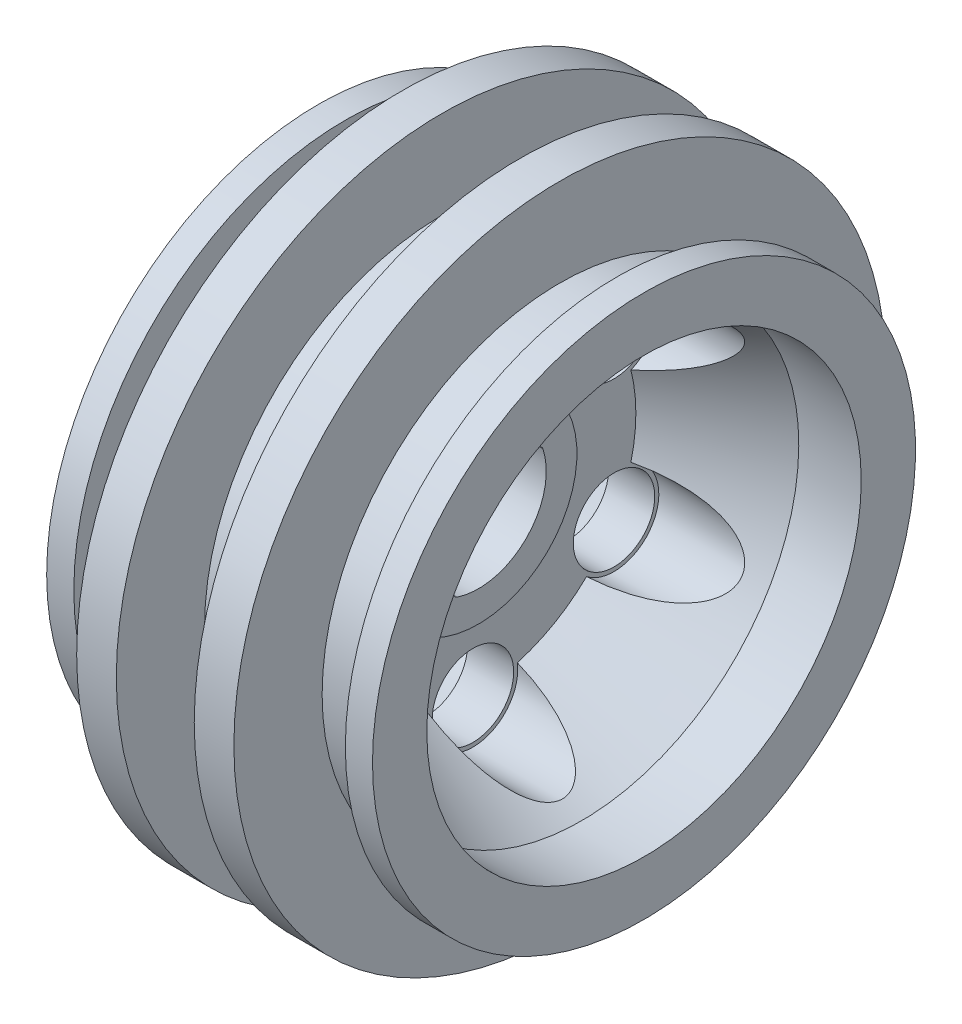
from build123d import *

# Parameters (mm, degrees)
CUT_EXTRUDE1_REACH        = 14.668
SKETCH2_R                 = 1.5
CUT_EXTRUDE2_REACH        = 15.519
SKETCH4_R                 = 1.65
CUT_EXTRUDE3_DEPTH        = 14.629380147
FILLET1_R                 = 0.2
CUT_EXTRUDE4_REACH        = 14.668
CUT_EXTRUDE5_DEPTH        = 0.5
CIRPATTERN1_COUNT         = 6
CIRPATTERN2_COUNT         = 6
CIRPATTERN2_COPY_1_REACH  = 14.668
CIRPATTERN2_COPY_2_REACH  = 14.668
CIRPATTERN2_COPY_3_REACH  = 14.668
CIRPATTERN2_COPY_4_REACH  = 14.668
CIRPATTERN2_COPY_5_REACH  = 14.668
CIRPATTERN2_COPY_6_REACH  = 14.668
CIRPATTERN2_COPY_7_REACH  = 14.668
CIRPATTERN2_COPY_8_REACH  = 14.668
CIRPATTERN2_COPY_9_REACH  = 14.668
CIRPATTERN2_COPY_10_REACH = 14.668
CIRPATTERN2_COPY_11_REACH = 14.668
CIRPATTERN2_COPY_12_REACH = 14.668
CIRPATTERN2_COPY_13_REACH = 14.668
CIRPATTERN2_COPY_14_REACH = 14.668
CIRPATTERN2_COPY_15_REACH = 14.668
CIRPATTERN2_COPY_16_REACH = 14.668
CIRPATTERN2_COPY_17_REACH = 14.668
CIRPATTERN2_COPY_18_REACH = 14.668
CIRPATTERN2_COPY_19_REACH = 14.668
CIRPATTERN2_COPY_20_REACH = 14.668
CIRPATTERN2_COPY_21_REACH = 14.668
CIRPATTERN2_COPY_22_REACH = 14.668
CIRPATTERN2_COPY_23_REACH = 14.668
CIRPATTERN2_COPY_24_REACH = 14.668
CIRPATTERN2_COPY_25_REACH = 14.668
CIRPATTERN2_COPY_26_REACH = 14.668
CIRPATTERN2_COPY_27_REACH = 14.668
CIRPATTERN2_COPY_28_REACH = 14.668
CIRPATTERN2_COPY_29_REACH = 14.668
CIRPATTERN2_COPY_30_REACH = 14.668


with BuildPart() as part:
    # Sketch1 → Revolve1 (revolve)
    with BuildSketch(Plane.XY, mode=Mode.PRIVATE) as revolve1_sk:
        Polygon((-0.1, 0), (-0.1, 3.63), (-0.3, 3.63), (-0.3, 6), (3.7, 8), (-2, 8), (-2, 3.63), (-7.7, 3.63), (-7.7, 0), align=None)
    revolve(revolve1_sk.sketch.rotate(Axis((0, 0, 0), (1, 0, 0)), 90), axis=Axis((0, 0, 0), (1, 0, 0)))

    # Sketch2 → Cut-Extrude1 (cut, up to next)
    with BuildSketch(Plane.ZY.offset(2), mode=Mode.PRIVATE) as cut_extrude1_sk1:
        with Locations((0, 6)):
            Circle(SKETCH2_R)
    cut_extrude1_tool1 = extrude(cut_extrude1_sk1.sketch, amount=-CUT_EXTRUDE1_REACH, mode=Mode.PRIVATE) & part.part
    # Sketch2 → Cut-Extrude1 (cut, up to next)
    with BuildSketch(Plane.ZY.offset(2), mode=Mode.PRIVATE) as cut_extrude1_sk2:
        with Locations((5.196152423, 3)):
            Circle(SKETCH2_R)
    cut_extrude1_tool2 = extrude(cut_extrude1_sk2.sketch, amount=-CUT_EXTRUDE1_REACH, mode=Mode.PRIVATE) & part.part
    # Sketch2 → Cut-Extrude1 (cut, up to next)
    with BuildSketch(Plane.ZY.offset(2), mode=Mode.PRIVATE) as cut_extrude1_sk3:
        with Locations((5.196152423, -3)):
            Circle(SKETCH2_R)
    cut_extrude1_tool3 = extrude(cut_extrude1_sk3.sketch, amount=-CUT_EXTRUDE1_REACH, mode=Mode.PRIVATE) & part.part
    # Sketch2 → Cut-Extrude1 (cut, up to next)
    with BuildSketch(Plane.ZY.offset(2), mode=Mode.PRIVATE) as cut_extrude1_sk4:
        with Locations((0, -6)):
            Circle(SKETCH2_R)
    cut_extrude1_tool4 = extrude(cut_extrude1_sk4.sketch, amount=-CUT_EXTRUDE1_REACH, mode=Mode.PRIVATE) & part.part
    # Sketch2 → Cut-Extrude1 (cut, up to next)
    with BuildSketch(Plane.ZY.offset(2), mode=Mode.PRIVATE) as cut_extrude1_sk5:
        with Locations((-5.196152423, -3)):
            Circle(SKETCH2_R)
    cut_extrude1_tool5 = extrude(cut_extrude1_sk5.sketch, amount=-CUT_EXTRUDE1_REACH, mode=Mode.PRIVATE) & part.part
    # Sketch2 → Cut-Extrude1 (cut, up to next)
    with BuildSketch(Plane.ZY.offset(2), mode=Mode.PRIVATE) as cut_extrude1_sk6:
        with Locations((-5.196152423, 3)):
            Circle(SKETCH2_R)
    cut_extrude1_tool6 = extrude(cut_extrude1_sk6.sketch, amount=-CUT_EXTRUDE1_REACH, mode=Mode.PRIVATE) & part.part
    add(cut_extrude1_tool1.solids().sort_by_distance((-2, 6, 0))[0], mode=Mode.SUBTRACT)
    add(cut_extrude1_tool2.solids().sort_by_distance((-2, 3, 5.196152))[0], mode=Mode.SUBTRACT)
    add(cut_extrude1_tool3.solids().sort_by_distance((-2, -3, 5.196152))[0], mode=Mode.SUBTRACT)
    add(cut_extrude1_tool4.solids().sort_by_distance((-2, -6, 0))[0], mode=Mode.SUBTRACT)
    add(cut_extrude1_tool5.solids().sort_by_distance((-2, -3, -5.196152))[0], mode=Mode.SUBTRACT)
    add(cut_extrude1_tool6.solids().sort_by_distance((-2, 3, -5.196152))[0], mode=Mode.SUBTRACT)

    # Sketch4 → Cut-Extrude2 (cut, up to next)
    with BuildSketch(Plane(origin=(-0.3, 0, 0), x_dir=(0, 0, -1), z_dir=(1, 0, 0)), mode=Mode.PRIVATE) as cut_extrude2_sk1:
        with Locations((5.196152423, 3)):
            Circle(SKETCH4_R)
    cut_extrude2_tool1 = extrude(cut_extrude2_sk1.sketch, amount=CUT_EXTRUDE2_REACH, mode=Mode.PRIVATE) & part.part
    # Sketch4 → Cut-Extrude2 (cut, up to next)
    with BuildSketch(Plane(origin=(-0.3, 0, 0), x_dir=(0, 0, -1), z_dir=(1, 0, 0)), mode=Mode.PRIVATE) as cut_extrude2_sk2:
        with Locations((0, 6)):
            Circle(SKETCH4_R)
    cut_extrude2_tool2 = extrude(cut_extrude2_sk2.sketch, amount=CUT_EXTRUDE2_REACH, mode=Mode.PRIVATE) & part.part
    # Sketch4 → Cut-Extrude2 (cut, up to next)
    with BuildSketch(Plane(origin=(-0.3, 0, 0), x_dir=(0, 0, -1), z_dir=(1, 0, 0)), mode=Mode.PRIVATE) as cut_extrude2_sk3:
        with Locations((5.196152423, -3)):
            Circle(SKETCH4_R)
    cut_extrude2_tool3 = extrude(cut_extrude2_sk3.sketch, amount=CUT_EXTRUDE2_REACH, mode=Mode.PRIVATE) & part.part
    # Sketch4 → Cut-Extrude2 (cut, up to next)
    with BuildSketch(Plane(origin=(-0.3, 0, 0), x_dir=(0, 0, -1), z_dir=(1, 0, 0)), mode=Mode.PRIVATE) as cut_extrude2_sk4:
        with Locations((0, -6)):
            Circle(SKETCH4_R)
    cut_extrude2_tool4 = extrude(cut_extrude2_sk4.sketch, amount=CUT_EXTRUDE2_REACH, mode=Mode.PRIVATE) & part.part
    # Sketch4 → Cut-Extrude2 (cut, up to next)
    with BuildSketch(Plane(origin=(-0.3, 0, 0), x_dir=(0, 0, -1), z_dir=(1, 0, 0)), mode=Mode.PRIVATE) as cut_extrude2_sk5:
        with Locations((-5.196152423, -3)):
            Circle(SKETCH4_R)
    cut_extrude2_tool5 = extrude(cut_extrude2_sk5.sketch, amount=CUT_EXTRUDE2_REACH, mode=Mode.PRIVATE) & part.part
    # Sketch4 → Cut-Extrude2 (cut, up to next)
    with BuildSketch(Plane(origin=(-0.3, 0, 0), x_dir=(0, 0, -1), z_dir=(1, 0, 0)), mode=Mode.PRIVATE) as cut_extrude2_sk6:
        with Locations((-5.196152423, 3)):
            Circle(SKETCH4_R)
    cut_extrude2_tool6 = extrude(cut_extrude2_sk6.sketch, amount=CUT_EXTRUDE2_REACH, mode=Mode.PRIVATE) & part.part
    add(cut_extrude2_tool1.solids().sort_by_distance((-0.3, 3, -5.196152))[0], mode=Mode.SUBTRACT)
    add(cut_extrude2_tool2.solids().sort_by_distance((-0.3, 6, 0))[0], mode=Mode.SUBTRACT)
    add(cut_extrude2_tool3.solids().sort_by_distance((-0.3, -3, -5.196152))[0], mode=Mode.SUBTRACT)
    add(cut_extrude2_tool4.solids().sort_by_distance((-0.3, -6, 0))[0], mode=Mode.SUBTRACT)
    add(cut_extrude2_tool5.solids().sort_by_distance((-0.3, -3, 5.196152))[0], mode=Mode.SUBTRACT)
    add(cut_extrude2_tool6.solids().sort_by_distance((-0.3, 3, 5.196152))[0], mode=Mode.SUBTRACT)

    # Sketch5 → Cut-Extrude3 (cut, through all)
    with BuildSketch(Plane(origin=(-0.1, 0, 0), x_dir=(0, 0, -1), z_dir=(1, 0, 0))):
        with BuildLine():
            Line((0.913078393, 2.327291956), (0.913078393, 0.913078393))
            Line((0.913078393, 0.913078393), (2.327291956, 0.913078393))
            ThreePointArc((2.327291956, 0.913078393), (1.767766953, -1.767766953), (-0.913078393, -2.327291956))
            Line((-0.913078393, -2.327291956), (-0.913078393, -0.913078393))
            Line((-0.913078393, -0.913078393), (-2.327291956, -0.913078393))
            ThreePointArc((-2.327291956, -0.913078393), (-1.767766953, 1.767766953), (0.913078393, 2.327291956))
        make_face()
    extrude(amount=-CUT_EXTRUDE3_DEPTH, mode=Mode.SUBTRACT)

    # Fillet1
    fillet1_edges = [part.edges().sort_by_distance(p)[0] for p in [
        (-3.9, -0.913078393, 2.327291956),
        (-3.9, 2.327291956, -0.913078393),
        (-3.9, 0.913078393, -0.913078393),
        (-3.9, 0.913078393, -2.327291956),
        (-3.9, -2.327291956, 0.913078393),
        (-3.9, -0.913078393, 0.913078393),
    ]]
    fillet(fillet1_edges, radius=FILLET1_R)

    # Cut-Extrude4: up to this cone (the profile starts outside it)
    cut_extrude4_end = Plane(origin=(-2, 0, 0), z_dir=(1, 0, 0)).offset(-11.865246584) * Cone(1e-06, 16.482935688, 32.965870376, align=(Align.CENTER, Align.CENTER, Align.MIN), mode=Mode.PRIVATE)
    # Sketch6 → Cut-Extrude4 (cut, up to the surface)
    with BuildSketch(Plane.ZY.offset(2), mode=Mode.PRIVATE) as cut_extrude4_sk1:
        with BuildLine():
            ThreePointArc((5.196152423, 0.7), (4.496152423, 0), (5.196152423, -0.7))
            ThreePointArc((5.196152423, -0.7), (6.031248458, -0.85696136), (6.752363789, -1.306422076))
            ThreePointArc((6.752363789, -1.306422076), (6.962711296, -1.350388021), (7.101582132, -1.186394213))
            ThreePointArc((7.101582132, -1.186394213), (7.2, 0), (7.101582132, 1.186394213))
            ThreePointArc((7.101582132, 1.186394213), (6.962711296, 1.350388021), (6.752363789, 1.306422076))
            ThreePointArc((6.752363789, 1.306422076), (6.031248458, 0.85696136), (5.196152423, 0.7))
        make_face()
    cut_extrude4_tool1 = extrude(cut_extrude4_sk1.sketch, amount=-CUT_EXTRUDE4_REACH, mode=Mode.PRIVATE) - cut_extrude4_end
    cut_extrude4 = cut_extrude4_tool1.solids().sort_by_distance((-2, 0, 6.076736))[0]
    add(cut_extrude4, mode=Mode.SUBTRACT)

    # Sketch6_2 → Cut-Extrude5 (cut)
    with BuildSketch(Plane.ZY.offset(2)):
        with BuildLine():
            ThreePointArc((5.196152423, 0.7), (4.496152423, 0), (5.196152423, -0.7))
            ThreePointArc((5.196152423, -0.7), (6.031248458, -0.85696136), (6.752363789, -1.306422076))
            ThreePointArc((6.752363789, -1.306422076), (6.962711296, -1.350388021), (7.101582132, -1.186394213))
            ThreePointArc((7.101582132, -1.186394213), (7.2, 0), (7.101582132, 1.186394213))
            ThreePointArc((7.101582132, 1.186394213), (6.962711296, 1.350388021), (6.752363789, 1.306422076))
            ThreePointArc((6.752363789, 1.306422076), (6.031248458, 0.85696136), (5.196152423, 0.7))
        make_face()
    cut_extrude5 = extrude(amount=-CUT_EXTRUDE5_DEPTH, mode=Mode.SUBTRACT)

    # CirPattern1: Cut-Extrude4 ×6 about axis
    cirpattern1_axis = Axis((0, 0, 0), (1, 0, 0))
    for i in range(1, CIRPATTERN1_COUNT):
        add(cut_extrude4.rotate(cirpattern1_axis, i * 360 / CIRPATTERN1_COUNT), mode=Mode.SUBTRACT)

    # CirPattern2: Cut-Extrude5 ×6 about axis
    cirpattern2_axis = Axis((0, 0, 0), (1, 0, 0))
    for i in range(1, CIRPATTERN2_COUNT):
        add(cut_extrude5.rotate(cirpattern2_axis, i * 360 / CIRPATTERN2_COUNT), mode=Mode.SUBTRACT)

    # CirPattern2 copy 1: up to this cone (the profile starts outside it)
    cirpattern2_copy_1_end = Plane(origin=(-2, 0, 0), z_dir=(1, 0, 0)).offset(-11.865246584) * Cone(1e-06, 16.482935688, 32.965870376, align=(Align.CENTER, Align.CENTER, Align.MIN), mode=Mode.PRIVATE)
    # CirPattern2 copy 1 sketch → CirPattern2 copy 1 (cut, up to the surface)
    with BuildSketch(Plane(origin=(-2, 0, 0), x_dir=(0, -0.8660254037844388, -0.4999999999999998), z_dir=(-1, 0, 0)), mode=Mode.PRIVATE) as cirpattern2_copy_1_sk1:
        with BuildLine():
            ThreePointArc((5.196152423, 0.7), (4.496152423, 0), (5.196152423, -0.7))
            ThreePointArc((5.196152423, -0.7), (6.031248458, -0.85696136), (6.752363789, -1.306422076))
            ThreePointArc((6.752363789, -1.306422076), (6.962711296, -1.350388021), (7.101582132, -1.186394213))
            ThreePointArc((7.101582132, -1.186394213), (7.2, 0), (7.101582132, 1.186394213))
            ThreePointArc((7.101582132, 1.186394213), (6.962711296, 1.350388021), (6.752363789, 1.306422076))
            ThreePointArc((6.752363789, 1.306422076), (6.031248458, 0.85696136), (5.196152423, 0.7))
        make_face()
    cirpattern2_copy_1_tool1 = extrude(cirpattern2_copy_1_sk1.sketch, amount=-CIRPATTERN2_COPY_1_REACH, mode=Mode.PRIVATE) - cirpattern2_copy_1_end
    add(cirpattern2_copy_1_tool1.solids().sort_by_distance((-2, 0, 6.076736))[0], mode=Mode.SUBTRACT)

    # CirPattern2 copy 2: up to this cone (the profile starts outside it)
    cirpattern2_copy_2_end = Plane(origin=(-2, 0, 0), z_dir=(1, 0, 0)).offset(-11.865246584) * Cone(1e-06, 16.482935688, 32.965870376, align=(Align.CENTER, Align.CENTER, Align.MIN), mode=Mode.PRIVATE)
    # CirPattern2 copy 2 sketch → CirPattern2 copy 2 (cut, up to the surface)
    with BuildSketch(Plane(origin=(-2, 0, 0), x_dir=(0, 0, -1), z_dir=(-1, 0, 0)), mode=Mode.PRIVATE) as cirpattern2_copy_2_sk1:
        with BuildLine():
            ThreePointArc((5.196152423, 0.7), (4.496152423, 0), (5.196152423, -0.7))
            ThreePointArc((5.196152423, -0.7), (6.031248458, -0.85696136), (6.752363789, -1.306422076))
            ThreePointArc((6.752363789, -1.306422076), (6.962711296, -1.350388021), (7.101582132, -1.186394213))
            ThreePointArc((7.101582132, -1.186394213), (7.2, 0), (7.101582132, 1.186394213))
            ThreePointArc((7.101582132, 1.186394213), (6.962711296, 1.350388021), (6.752363789, 1.306422076))
            ThreePointArc((6.752363789, 1.306422076), (6.031248458, 0.85696136), (5.196152423, 0.7))
        make_face()
    cirpattern2_copy_2_tool1 = extrude(cirpattern2_copy_2_sk1.sketch, amount=-CIRPATTERN2_COPY_2_REACH, mode=Mode.PRIVATE) - cirpattern2_copy_2_end
    add(cirpattern2_copy_2_tool1.solids().sort_by_distance((-2, 0, 6.076736))[0], mode=Mode.SUBTRACT)

    # CirPattern2 copy 3: up to this cone (the profile starts outside it)
    cirpattern2_copy_3_end = Plane(origin=(-2, 0, 0), z_dir=(1, 0, 0)).offset(-11.865246584) * Cone(1e-06, 16.482935688, 32.965870376, align=(Align.CENTER, Align.CENTER, Align.MIN), mode=Mode.PRIVATE)
    # CirPattern2 copy 3 sketch → CirPattern2 copy 3 (cut, up to the surface)
    with BuildSketch(Plane(origin=(-2, 0, 0), x_dir=(0, 0.8660254037844385, -0.5000000000000002), z_dir=(-1, 0, 0)), mode=Mode.PRIVATE) as cirpattern2_copy_3_sk1:
        with BuildLine():
            ThreePointArc((5.196152423, 0.7), (4.496152423, 0), (5.196152423, -0.7))
            ThreePointArc((5.196152423, -0.7), (6.031248458, -0.85696136), (6.752363789, -1.306422076))
            ThreePointArc((6.752363789, -1.306422076), (6.962711296, -1.350388021), (7.101582132, -1.186394213))
            ThreePointArc((7.101582132, -1.186394213), (7.2, 0), (7.101582132, 1.186394213))
            ThreePointArc((7.101582132, 1.186394213), (6.962711296, 1.350388021), (6.752363789, 1.306422076))
            ThreePointArc((6.752363789, 1.306422076), (6.031248458, 0.85696136), (5.196152423, 0.7))
        make_face()
    cirpattern2_copy_3_tool1 = extrude(cirpattern2_copy_3_sk1.sketch, amount=-CIRPATTERN2_COPY_3_REACH, mode=Mode.PRIVATE) - cirpattern2_copy_3_end
    add(cirpattern2_copy_3_tool1.solids().sort_by_distance((-2, 0, 6.076736))[0], mode=Mode.SUBTRACT)

    # CirPattern2 copy 4: up to this cone (the profile starts outside it)
    cirpattern2_copy_4_end = Plane(origin=(-2, 0, 0), z_dir=(1, 0, 0)).offset(-11.865246584) * Cone(1e-06, 16.482935688, 32.965870376, align=(Align.CENTER, Align.CENTER, Align.MIN), mode=Mode.PRIVATE)
    # CirPattern2 copy 4 sketch → CirPattern2 copy 4 (cut, up to the surface)
    with BuildSketch(Plane(origin=(-2, 0, 0), x_dir=(0, 0.866025403784439, 0.4999999999999994), z_dir=(-1, 0, 0)), mode=Mode.PRIVATE) as cirpattern2_copy_4_sk1:
        with BuildLine():
            ThreePointArc((5.196152423, 0.7), (4.496152423, 0), (5.196152423, -0.7))
            ThreePointArc((5.196152423, -0.7), (6.031248458, -0.85696136), (6.752363789, -1.306422076))
            ThreePointArc((6.752363789, -1.306422076), (6.962711296, -1.350388021), (7.101582132, -1.186394213))
            ThreePointArc((7.101582132, -1.186394213), (7.2, 0), (7.101582132, 1.186394213))
            ThreePointArc((7.101582132, 1.186394213), (6.962711296, 1.350388021), (6.752363789, 1.306422076))
            ThreePointArc((6.752363789, 1.306422076), (6.031248458, 0.85696136), (5.196152423, 0.7))
        make_face()
    cirpattern2_copy_4_tool1 = extrude(cirpattern2_copy_4_sk1.sketch, amount=-CIRPATTERN2_COPY_4_REACH, mode=Mode.PRIVATE) - cirpattern2_copy_4_end
    add(cirpattern2_copy_4_tool1.solids().sort_by_distance((-2, 0, 6.076736))[0], mode=Mode.SUBTRACT)

    # CirPattern2 copy 5: up to this cone (the profile starts outside it)
    cirpattern2_copy_5_end = Plane(origin=(-2, 0, 0), z_dir=(1, 0, 0)).offset(-11.865246584) * Cone(1e-06, 16.482935688, 32.965870376, align=(Align.CENTER, Align.CENTER, Align.MIN), mode=Mode.PRIVATE)
    # CirPattern2 copy 5 sketch → CirPattern2 copy 5 (cut, up to the surface)
    with BuildSketch(Plane.ZY.offset(2), mode=Mode.PRIVATE) as cirpattern2_copy_5_sk1:
        with BuildLine():
            ThreePointArc((5.196152423, 0.7), (4.496152423, 0), (5.196152423, -0.7))
            ThreePointArc((5.196152423, -0.7), (6.031248458, -0.85696136), (6.752363789, -1.306422076))
            ThreePointArc((6.752363789, -1.306422076), (6.962711296, -1.350388021), (7.101582132, -1.186394213))
            ThreePointArc((7.101582132, -1.186394213), (7.2, 0), (7.101582132, 1.186394213))
            ThreePointArc((7.101582132, 1.186394213), (6.962711296, 1.350388021), (6.752363789, 1.306422076))
            ThreePointArc((6.752363789, 1.306422076), (6.031248458, 0.85696136), (5.196152423, 0.7))
        make_face()
    cirpattern2_copy_5_tool1 = extrude(cirpattern2_copy_5_sk1.sketch, amount=-CIRPATTERN2_COPY_5_REACH, mode=Mode.PRIVATE) - cirpattern2_copy_5_end
    add(cirpattern2_copy_5_tool1.solids().sort_by_distance((-2, 0, 6.076736))[0], mode=Mode.SUBTRACT)

    # CirPattern2 copy 6: up to this cone (the profile starts outside it)
    cirpattern2_copy_6_end = Plane(origin=(-2, 0, 0), z_dir=(1, 0, 0)).offset(-11.865246584) * Cone(1e-06, 16.482935688, 32.965870376, align=(Align.CENTER, Align.CENTER, Align.MIN), mode=Mode.PRIVATE)
    # CirPattern2 copy 6 sketch → CirPattern2 copy 6 (cut, up to the surface)
    with BuildSketch(Plane(origin=(-2, 0, 0), x_dir=(0, 0, -1), z_dir=(-1, 0, 0)), mode=Mode.PRIVATE) as cirpattern2_copy_6_sk1:
        with BuildLine():
            ThreePointArc((5.196152423, 0.7), (4.496152423, 0), (5.196152423, -0.7))
            ThreePointArc((5.196152423, -0.7), (6.031248458, -0.85696136), (6.752363789, -1.306422076))
            ThreePointArc((6.752363789, -1.306422076), (6.962711296, -1.350388021), (7.101582132, -1.186394213))
            ThreePointArc((7.101582132, -1.186394213), (7.2, 0), (7.101582132, 1.186394213))
            ThreePointArc((7.101582132, 1.186394213), (6.962711296, 1.350388021), (6.752363789, 1.306422076))
            ThreePointArc((6.752363789, 1.306422076), (6.031248458, 0.85696136), (5.196152423, 0.7))
        make_face()
    cirpattern2_copy_6_tool1 = extrude(cirpattern2_copy_6_sk1.sketch, amount=-CIRPATTERN2_COPY_6_REACH, mode=Mode.PRIVATE) - cirpattern2_copy_6_end
    add(cirpattern2_copy_6_tool1.solids().sort_by_distance((-2, 0, 6.076736))[0], mode=Mode.SUBTRACT)

    # CirPattern2 copy 7: up to this cone (the profile starts outside it)
    cirpattern2_copy_7_end = Plane(origin=(-2, 0, 0), z_dir=(1, 0, 0)).offset(-11.865246584) * Cone(1e-06, 16.482935688, 32.965870376, align=(Align.CENTER, Align.CENTER, Align.MIN), mode=Mode.PRIVATE)
    # CirPattern2 copy 7 sketch → CirPattern2 copy 7 (cut, up to the surface)
    with BuildSketch(Plane(origin=(-2, 0, 0), x_dir=(0, 0.8660254037844384, -0.5000000000000003), z_dir=(-1, 0, 0)), mode=Mode.PRIVATE) as cirpattern2_copy_7_sk1:
        with BuildLine():
            ThreePointArc((5.196152423, 0.7), (4.496152423, 0), (5.196152423, -0.7))
            ThreePointArc((5.196152423, -0.7), (6.031248458, -0.85696136), (6.752363789, -1.306422076))
            ThreePointArc((6.752363789, -1.306422076), (6.962711296, -1.350388021), (7.101582132, -1.186394213))
            ThreePointArc((7.101582132, -1.186394213), (7.2, 0), (7.101582132, 1.186394213))
            ThreePointArc((7.101582132, 1.186394213), (6.962711296, 1.350388021), (6.752363789, 1.306422076))
            ThreePointArc((6.752363789, 1.306422076), (6.031248458, 0.85696136), (5.196152423, 0.7))
        make_face()
    cirpattern2_copy_7_tool1 = extrude(cirpattern2_copy_7_sk1.sketch, amount=-CIRPATTERN2_COPY_7_REACH, mode=Mode.PRIVATE) - cirpattern2_copy_7_end
    add(cirpattern2_copy_7_tool1.solids().sort_by_distance((-2, 0, 6.076736))[0], mode=Mode.SUBTRACT)

    # CirPattern2 copy 8: up to this cone (the profile starts outside it)
    cirpattern2_copy_8_end = Plane(origin=(-2, 0, 0), z_dir=(1, 0, 0)).offset(-11.865246584) * Cone(1e-06, 16.482935688, 32.965870376, align=(Align.CENTER, Align.CENTER, Align.MIN), mode=Mode.PRIVATE)
    # CirPattern2 copy 8 sketch → CirPattern2 copy 8 (cut, up to the surface)
    with BuildSketch(Plane(origin=(-2, 0, 0), x_dir=(0, 0.8660254037844388, 0.49999999999999967), z_dir=(-1, 0, 0)), mode=Mode.PRIVATE) as cirpattern2_copy_8_sk1:
        with BuildLine():
            ThreePointArc((5.196152423, 0.7), (4.496152423, 0), (5.196152423, -0.7))
            ThreePointArc((5.196152423, -0.7), (6.031248458, -0.85696136), (6.752363789, -1.306422076))
            ThreePointArc((6.752363789, -1.306422076), (6.962711296, -1.350388021), (7.101582132, -1.186394213))
            ThreePointArc((7.101582132, -1.186394213), (7.2, 0), (7.101582132, 1.186394213))
            ThreePointArc((7.101582132, 1.186394213), (6.962711296, 1.350388021), (6.752363789, 1.306422076))
            ThreePointArc((6.752363789, 1.306422076), (6.031248458, 0.85696136), (5.196152423, 0.7))
        make_face()
    cirpattern2_copy_8_tool1 = extrude(cirpattern2_copy_8_sk1.sketch, amount=-CIRPATTERN2_COPY_8_REACH, mode=Mode.PRIVATE) - cirpattern2_copy_8_end
    add(cirpattern2_copy_8_tool1.solids().sort_by_distance((-2, 0, 6.076736))[0], mode=Mode.SUBTRACT)

    # CirPattern2 copy 9: up to this cone (the profile starts outside it)
    cirpattern2_copy_9_end = Plane(origin=(-2, 0, 0), z_dir=(1, 0, 0)).offset(-11.865246584) * Cone(1e-06, 16.482935688, 32.965870376, align=(Align.CENTER, Align.CENTER, Align.MIN), mode=Mode.PRIVATE)
    # CirPattern2 copy 9 sketch → CirPattern2 copy 9 (cut, up to the surface)
    with BuildSketch(Plane.ZY.offset(2), mode=Mode.PRIVATE) as cirpattern2_copy_9_sk1:
        with BuildLine():
            ThreePointArc((5.196152423, 0.7), (4.496152423, 0), (5.196152423, -0.7))
            ThreePointArc((5.196152423, -0.7), (6.031248458, -0.85696136), (6.752363789, -1.306422076))
            ThreePointArc((6.752363789, -1.306422076), (6.962711296, -1.350388021), (7.101582132, -1.186394213))
            ThreePointArc((7.101582132, -1.186394213), (7.2, 0), (7.101582132, 1.186394213))
            ThreePointArc((7.101582132, 1.186394213), (6.962711296, 1.350388021), (6.752363789, 1.306422076))
            ThreePointArc((6.752363789, 1.306422076), (6.031248458, 0.85696136), (5.196152423, 0.7))
        make_face()
    cirpattern2_copy_9_tool1 = extrude(cirpattern2_copy_9_sk1.sketch, amount=-CIRPATTERN2_COPY_9_REACH, mode=Mode.PRIVATE) - cirpattern2_copy_9_end
    add(cirpattern2_copy_9_tool1.solids().sort_by_distance((-2, 0, 6.076736))[0], mode=Mode.SUBTRACT)

    # CirPattern2 copy 10: up to this cone (the profile starts outside it)
    cirpattern2_copy_10_end = Plane(origin=(-2, 0, 0), z_dir=(1, 0, 0)).offset(-11.865246584) * Cone(1e-06, 16.482935688, 32.965870376, align=(Align.CENTER, Align.CENTER, Align.MIN), mode=Mode.PRIVATE)
    # CirPattern2 copy 10 sketch → CirPattern2 copy 10 (cut, up to the surface)
    with BuildSketch(Plane(origin=(-2, 0, 0), x_dir=(0, -0.8660254037844386, 0.5), z_dir=(-1, 0, 0)), mode=Mode.PRIVATE) as cirpattern2_copy_10_sk1:
        with BuildLine():
            ThreePointArc((5.196152423, 0.7), (4.496152423, 0), (5.196152423, -0.7))
            ThreePointArc((5.196152423, -0.7), (6.031248458, -0.85696136), (6.752363789, -1.306422076))
            ThreePointArc((6.752363789, -1.306422076), (6.962711296, -1.350388021), (7.101582132, -1.186394213))
            ThreePointArc((7.101582132, -1.186394213), (7.2, 0), (7.101582132, 1.186394213))
            ThreePointArc((7.101582132, 1.186394213), (6.962711296, 1.350388021), (6.752363789, 1.306422076))
            ThreePointArc((6.752363789, 1.306422076), (6.031248458, 0.85696136), (5.196152423, 0.7))
        make_face()
    cirpattern2_copy_10_tool1 = extrude(cirpattern2_copy_10_sk1.sketch, amount=-CIRPATTERN2_COPY_10_REACH, mode=Mode.PRIVATE) - cirpattern2_copy_10_end
    add(cirpattern2_copy_10_tool1.solids().sort_by_distance((-2, 0, 6.076736))[0], mode=Mode.SUBTRACT)

    # CirPattern2 copy 11: up to this cone (the profile starts outside it)
    cirpattern2_copy_11_end = Plane(origin=(-2, 0, 0), z_dir=(1, 0, 0)).offset(-11.865246584) * Cone(1e-06, 16.482935688, 32.965870376, align=(Align.CENTER, Align.CENTER, Align.MIN), mode=Mode.PRIVATE)
    # CirPattern2 copy 11 sketch → CirPattern2 copy 11 (cut, up to the surface)
    with BuildSketch(Plane(origin=(-2, 0, 0), x_dir=(0, 0.8660254037844385, -0.5000000000000002), z_dir=(-1, 0, 0)), mode=Mode.PRIVATE) as cirpattern2_copy_11_sk1:
        with BuildLine():
            ThreePointArc((5.196152423, 0.7), (4.496152423, 0), (5.196152423, -0.7))
            ThreePointArc((5.196152423, -0.7), (6.031248458, -0.85696136), (6.752363789, -1.306422076))
            ThreePointArc((6.752363789, -1.306422076), (6.962711296, -1.350388021), (7.101582132, -1.186394213))
            ThreePointArc((7.101582132, -1.186394213), (7.2, 0), (7.101582132, 1.186394213))
            ThreePointArc((7.101582132, 1.186394213), (6.962711296, 1.350388021), (6.752363789, 1.306422076))
            ThreePointArc((6.752363789, 1.306422076), (6.031248458, 0.85696136), (5.196152423, 0.7))
        make_face()
    cirpattern2_copy_11_tool1 = extrude(cirpattern2_copy_11_sk1.sketch, amount=-CIRPATTERN2_COPY_11_REACH, mode=Mode.PRIVATE) - cirpattern2_copy_11_end
    add(cirpattern2_copy_11_tool1.solids().sort_by_distance((-2, 0, 6.076736))[0], mode=Mode.SUBTRACT)

    # CirPattern2 copy 12: up to this cone (the profile starts outside it)
    cirpattern2_copy_12_end = Plane(origin=(-2, 0, 0), z_dir=(1, 0, 0)).offset(-11.865246584) * Cone(1e-06, 16.482935688, 32.965870376, align=(Align.CENTER, Align.CENTER, Align.MIN), mode=Mode.PRIVATE)
    # CirPattern2 copy 12 sketch → CirPattern2 copy 12 (cut, up to the surface)
    with BuildSketch(Plane(origin=(-2, 0, 0), x_dir=(0, 0.8660254037844388, 0.49999999999999967), z_dir=(-1, 0, 0)), mode=Mode.PRIVATE) as cirpattern2_copy_12_sk1:
        with BuildLine():
            ThreePointArc((5.196152423, 0.7), (4.496152423, 0), (5.196152423, -0.7))
            ThreePointArc((5.196152423, -0.7), (6.031248458, -0.85696136), (6.752363789, -1.306422076))
            ThreePointArc((6.752363789, -1.306422076), (6.962711296, -1.350388021), (7.101582132, -1.186394213))
            ThreePointArc((7.101582132, -1.186394213), (7.2, 0), (7.101582132, 1.186394213))
            ThreePointArc((7.101582132, 1.186394213), (6.962711296, 1.350388021), (6.752363789, 1.306422076))
            ThreePointArc((6.752363789, 1.306422076), (6.031248458, 0.85696136), (5.196152423, 0.7))
        make_face()
    cirpattern2_copy_12_tool1 = extrude(cirpattern2_copy_12_sk1.sketch, amount=-CIRPATTERN2_COPY_12_REACH, mode=Mode.PRIVATE) - cirpattern2_copy_12_end
    add(cirpattern2_copy_12_tool1.solids().sort_by_distance((-2, 0, 6.076736))[0], mode=Mode.SUBTRACT)

    # CirPattern2 copy 13: up to this cone (the profile starts outside it)
    cirpattern2_copy_13_end = Plane(origin=(-2, 0, 0), z_dir=(1, 0, 0)).offset(-11.865246584) * Cone(1e-06, 16.482935688, 32.965870376, align=(Align.CENTER, Align.CENTER, Align.MIN), mode=Mode.PRIVATE)
    # CirPattern2 copy 13 sketch → CirPattern2 copy 13 (cut, up to the surface)
    with BuildSketch(Plane.ZY.offset(2), mode=Mode.PRIVATE) as cirpattern2_copy_13_sk1:
        with BuildLine():
            ThreePointArc((5.196152423, 0.7), (4.496152423, 0), (5.196152423, -0.7))
            ThreePointArc((5.196152423, -0.7), (6.031248458, -0.85696136), (6.752363789, -1.306422076))
            ThreePointArc((6.752363789, -1.306422076), (6.962711296, -1.350388021), (7.101582132, -1.186394213))
            ThreePointArc((7.101582132, -1.186394213), (7.2, 0), (7.101582132, 1.186394213))
            ThreePointArc((7.101582132, 1.186394213), (6.962711296, 1.350388021), (6.752363789, 1.306422076))
            ThreePointArc((6.752363789, 1.306422076), (6.031248458, 0.85696136), (5.196152423, 0.7))
        make_face()
    cirpattern2_copy_13_tool1 = extrude(cirpattern2_copy_13_sk1.sketch, amount=-CIRPATTERN2_COPY_13_REACH, mode=Mode.PRIVATE) - cirpattern2_copy_13_end
    add(cirpattern2_copy_13_tool1.solids().sort_by_distance((-2, 0, 6.076736))[0], mode=Mode.SUBTRACT)

    # CirPattern2 copy 14: up to this cone (the profile starts outside it)
    cirpattern2_copy_14_end = Plane(origin=(-2, 0, 0), z_dir=(1, 0, 0)).offset(-11.865246584) * Cone(1e-06, 16.482935688, 32.965870376, align=(Align.CENTER, Align.CENTER, Align.MIN), mode=Mode.PRIVATE)
    # CirPattern2 copy 14 sketch → CirPattern2 copy 14 (cut, up to the surface)
    with BuildSketch(Plane(origin=(-2, 0, 0), x_dir=(0, -0.8660254037844383, 0.5000000000000006), z_dir=(-1, 0, 0)), mode=Mode.PRIVATE) as cirpattern2_copy_14_sk1:
        with BuildLine():
            ThreePointArc((5.196152423, 0.7), (4.496152423, 0), (5.196152423, -0.7))
            ThreePointArc((5.196152423, -0.7), (6.031248458, -0.85696136), (6.752363789, -1.306422076))
            ThreePointArc((6.752363789, -1.306422076), (6.962711296, -1.350388021), (7.101582132, -1.186394213))
            ThreePointArc((7.101582132, -1.186394213), (7.2, 0), (7.101582132, 1.186394213))
            ThreePointArc((7.101582132, 1.186394213), (6.962711296, 1.350388021), (6.752363789, 1.306422076))
            ThreePointArc((6.752363789, 1.306422076), (6.031248458, 0.85696136), (5.196152423, 0.7))
        make_face()
    cirpattern2_copy_14_tool1 = extrude(cirpattern2_copy_14_sk1.sketch, amount=-CIRPATTERN2_COPY_14_REACH, mode=Mode.PRIVATE) - cirpattern2_copy_14_end
    add(cirpattern2_copy_14_tool1.solids().sort_by_distance((-2, 0, 6.076736))[0], mode=Mode.SUBTRACT)

    # CirPattern2 copy 15: up to this cone (the profile starts outside it)
    cirpattern2_copy_15_end = Plane(origin=(-2, 0, 0), z_dir=(1, 0, 0)).offset(-11.865246584) * Cone(1e-06, 16.482935688, 32.965870376, align=(Align.CENTER, Align.CENTER, Align.MIN), mode=Mode.PRIVATE)
    # CirPattern2 copy 15 sketch → CirPattern2 copy 15 (cut, up to the surface)
    with BuildSketch(Plane(origin=(-2, 0, 0), x_dir=(0, -0.8660254037844387, -0.5), z_dir=(-1, 0, 0)), mode=Mode.PRIVATE) as cirpattern2_copy_15_sk1:
        with BuildLine():
            ThreePointArc((5.196152423, 0.7), (4.496152423, 0), (5.196152423, -0.7))
            ThreePointArc((5.196152423, -0.7), (6.031248458, -0.85696136), (6.752363789, -1.306422076))
            ThreePointArc((6.752363789, -1.306422076), (6.962711296, -1.350388021), (7.101582132, -1.186394213))
            ThreePointArc((7.101582132, -1.186394213), (7.2, 0), (7.101582132, 1.186394213))
            ThreePointArc((7.101582132, 1.186394213), (6.962711296, 1.350388021), (6.752363789, 1.306422076))
            ThreePointArc((6.752363789, 1.306422076), (6.031248458, 0.85696136), (5.196152423, 0.7))
        make_face()
    cirpattern2_copy_15_tool1 = extrude(cirpattern2_copy_15_sk1.sketch, amount=-CIRPATTERN2_COPY_15_REACH, mode=Mode.PRIVATE) - cirpattern2_copy_15_end
    add(cirpattern2_copy_15_tool1.solids().sort_by_distance((-2, 0, 6.076736))[0], mode=Mode.SUBTRACT)

    # CirPattern2 copy 16: up to this cone (the profile starts outside it)
    cirpattern2_copy_16_end = Plane(origin=(-2, 0, 0), z_dir=(1, 0, 0)).offset(-11.865246584) * Cone(1e-06, 16.482935688, 32.965870376, align=(Align.CENTER, Align.CENTER, Align.MIN), mode=Mode.PRIVATE)
    # CirPattern2 copy 16 sketch → CirPattern2 copy 16 (cut, up to the surface)
    with BuildSketch(Plane(origin=(-2, 0, 0), x_dir=(0, 0.866025403784439, 0.4999999999999994), z_dir=(-1, 0, 0)), mode=Mode.PRIVATE) as cirpattern2_copy_16_sk1:
        with BuildLine():
            ThreePointArc((5.196152423, 0.7), (4.496152423, 0), (5.196152423, -0.7))
            ThreePointArc((5.196152423, -0.7), (6.031248458, -0.85696136), (6.752363789, -1.306422076))
            ThreePointArc((6.752363789, -1.306422076), (6.962711296, -1.350388021), (7.101582132, -1.186394213))
            ThreePointArc((7.101582132, -1.186394213), (7.2, 0), (7.101582132, 1.186394213))
            ThreePointArc((7.101582132, 1.186394213), (6.962711296, 1.350388021), (6.752363789, 1.306422076))
            ThreePointArc((6.752363789, 1.306422076), (6.031248458, 0.85696136), (5.196152423, 0.7))
        make_face()
    cirpattern2_copy_16_tool1 = extrude(cirpattern2_copy_16_sk1.sketch, amount=-CIRPATTERN2_COPY_16_REACH, mode=Mode.PRIVATE) - cirpattern2_copy_16_end
    add(cirpattern2_copy_16_tool1.solids().sort_by_distance((-2, 0, 6.076736))[0], mode=Mode.SUBTRACT)

    # CirPattern2 copy 17: up to this cone (the profile starts outside it)
    cirpattern2_copy_17_end = Plane(origin=(-2, 0, 0), z_dir=(1, 0, 0)).offset(-11.865246584) * Cone(1e-06, 16.482935688, 32.965870376, align=(Align.CENTER, Align.CENTER, Align.MIN), mode=Mode.PRIVATE)
    # CirPattern2 copy 17 sketch → CirPattern2 copy 17 (cut, up to the surface)
    with BuildSketch(Plane.ZY.offset(2), mode=Mode.PRIVATE) as cirpattern2_copy_17_sk1:
        with BuildLine():
            ThreePointArc((5.196152423, 0.7), (4.496152423, 0), (5.196152423, -0.7))
            ThreePointArc((5.196152423, -0.7), (6.031248458, -0.85696136), (6.752363789, -1.306422076))
            ThreePointArc((6.752363789, -1.306422076), (6.962711296, -1.350388021), (7.101582132, -1.186394213))
            ThreePointArc((7.101582132, -1.186394213), (7.2, 0), (7.101582132, 1.186394213))
            ThreePointArc((7.101582132, 1.186394213), (6.962711296, 1.350388021), (6.752363789, 1.306422076))
            ThreePointArc((6.752363789, 1.306422076), (6.031248458, 0.85696136), (5.196152423, 0.7))
        make_face()
    cirpattern2_copy_17_tool1 = extrude(cirpattern2_copy_17_sk1.sketch, amount=-CIRPATTERN2_COPY_17_REACH, mode=Mode.PRIVATE) - cirpattern2_copy_17_end
    add(cirpattern2_copy_17_tool1.solids().sort_by_distance((-2, 0, 6.076736))[0], mode=Mode.SUBTRACT)

    # CirPattern2 copy 18: up to this cone (the profile starts outside it)
    cirpattern2_copy_18_end = Plane(origin=(-2, 0, 0), z_dir=(1, 0, 0)).offset(-11.865246584) * Cone(1e-06, 16.482935688, 32.965870376, align=(Align.CENTER, Align.CENTER, Align.MIN), mode=Mode.PRIVATE)
    # CirPattern2 copy 18 sketch → CirPattern2 copy 18 (cut, up to the surface)
    with BuildSketch(Plane(origin=(-2, 0, 0), x_dir=(0, -0.8660254037844383, 0.5000000000000006), z_dir=(-1, 0, 0)), mode=Mode.PRIVATE) as cirpattern2_copy_18_sk1:
        with BuildLine():
            ThreePointArc((5.196152423, 0.7), (4.496152423, 0), (5.196152423, -0.7))
            ThreePointArc((5.196152423, -0.7), (6.031248458, -0.85696136), (6.752363789, -1.306422076))
            ThreePointArc((6.752363789, -1.306422076), (6.962711296, -1.350388021), (7.101582132, -1.186394213))
            ThreePointArc((7.101582132, -1.186394213), (7.2, 0), (7.101582132, 1.186394213))
            ThreePointArc((7.101582132, 1.186394213), (6.962711296, 1.350388021), (6.752363789, 1.306422076))
            ThreePointArc((6.752363789, 1.306422076), (6.031248458, 0.85696136), (5.196152423, 0.7))
        make_face()
    cirpattern2_copy_18_tool1 = extrude(cirpattern2_copy_18_sk1.sketch, amount=-CIRPATTERN2_COPY_18_REACH, mode=Mode.PRIVATE) - cirpattern2_copy_18_end
    add(cirpattern2_copy_18_tool1.solids().sort_by_distance((-2, 0, 6.076736))[0], mode=Mode.SUBTRACT)

    # CirPattern2 copy 19: up to this cone (the profile starts outside it)
    cirpattern2_copy_19_end = Plane(origin=(-2, 0, 0), z_dir=(1, 0, 0)).offset(-11.865246584) * Cone(1e-06, 16.482935688, 32.965870376, align=(Align.CENTER, Align.CENTER, Align.MIN), mode=Mode.PRIVATE)
    # CirPattern2 copy 19 sketch → CirPattern2 copy 19 (cut, up to the surface)
    with BuildSketch(Plane(origin=(-2, 0, 0), x_dir=(0, -0.8660254037844392, -0.4999999999999991), z_dir=(-1, 0, 0)), mode=Mode.PRIVATE) as cirpattern2_copy_19_sk1:
        with BuildLine():
            ThreePointArc((5.196152423, 0.7), (4.496152423, 0), (5.196152423, -0.7))
            ThreePointArc((5.196152423, -0.7), (6.031248458, -0.85696136), (6.752363789, -1.306422076))
            ThreePointArc((6.752363789, -1.306422076), (6.962711296, -1.350388021), (7.101582132, -1.186394213))
            ThreePointArc((7.101582132, -1.186394213), (7.2, 0), (7.101582132, 1.186394213))
            ThreePointArc((7.101582132, 1.186394213), (6.962711296, 1.350388021), (6.752363789, 1.306422076))
            ThreePointArc((6.752363789, 1.306422076), (6.031248458, 0.85696136), (5.196152423, 0.7))
        make_face()
    cirpattern2_copy_19_tool1 = extrude(cirpattern2_copy_19_sk1.sketch, amount=-CIRPATTERN2_COPY_19_REACH, mode=Mode.PRIVATE) - cirpattern2_copy_19_end
    add(cirpattern2_copy_19_tool1.solids().sort_by_distance((-2, 0, 6.076736))[0], mode=Mode.SUBTRACT)

    # CirPattern2 copy 20: up to this cone (the profile starts outside it)
    cirpattern2_copy_20_end = Plane(origin=(-2, 0, 0), z_dir=(1, 0, 0)).offset(-11.865246584) * Cone(1e-06, 16.482935688, 32.965870376, align=(Align.CENTER, Align.CENTER, Align.MIN), mode=Mode.PRIVATE)
    # CirPattern2 copy 20 sketch → CirPattern2 copy 20 (cut, up to the surface)
    with BuildSketch(Plane(origin=(-2, 0, 0), x_dir=(0, 0, -1), z_dir=(-1, 0, 0)), mode=Mode.PRIVATE) as cirpattern2_copy_20_sk1:
        with BuildLine():
            ThreePointArc((5.196152423, 0.7), (4.496152423, 0), (5.196152423, -0.7))
            ThreePointArc((5.196152423, -0.7), (6.031248458, -0.85696136), (6.752363789, -1.306422076))
            ThreePointArc((6.752363789, -1.306422076), (6.962711296, -1.350388021), (7.101582132, -1.186394213))
            ThreePointArc((7.101582132, -1.186394213), (7.2, 0), (7.101582132, 1.186394213))
            ThreePointArc((7.101582132, 1.186394213), (6.962711296, 1.350388021), (6.752363789, 1.306422076))
            ThreePointArc((6.752363789, 1.306422076), (6.031248458, 0.85696136), (5.196152423, 0.7))
        make_face()
    cirpattern2_copy_20_tool1 = extrude(cirpattern2_copy_20_sk1.sketch, amount=-CIRPATTERN2_COPY_20_REACH, mode=Mode.PRIVATE) - cirpattern2_copy_20_end
    add(cirpattern2_copy_20_tool1.solids().sort_by_distance((-2, 0, 6.076736))[0], mode=Mode.SUBTRACT)

    # CirPattern2 copy 21: up to this cone (the profile starts outside it)
    cirpattern2_copy_21_end = Plane(origin=(-2, 0, 0), z_dir=(1, 0, 0)).offset(-11.865246584) * Cone(1e-06, 16.482935688, 32.965870376, align=(Align.CENTER, Align.CENTER, Align.MIN), mode=Mode.PRIVATE)
    # CirPattern2 copy 21 sketch → CirPattern2 copy 21 (cut, up to the surface)
    with BuildSketch(Plane.ZY.offset(2), mode=Mode.PRIVATE) as cirpattern2_copy_21_sk1:
        with BuildLine():
            ThreePointArc((5.196152423, 0.7), (4.496152423, 0), (5.196152423, -0.7))
            ThreePointArc((5.196152423, -0.7), (6.031248458, -0.85696136), (6.752363789, -1.306422076))
            ThreePointArc((6.752363789, -1.306422076), (6.962711296, -1.350388021), (7.101582132, -1.186394213))
            ThreePointArc((7.101582132, -1.186394213), (7.2, 0), (7.101582132, 1.186394213))
            ThreePointArc((7.101582132, 1.186394213), (6.962711296, 1.350388021), (6.752363789, 1.306422076))
            ThreePointArc((6.752363789, 1.306422076), (6.031248458, 0.85696136), (5.196152423, 0.7))
        make_face()
    cirpattern2_copy_21_tool1 = extrude(cirpattern2_copy_21_sk1.sketch, amount=-CIRPATTERN2_COPY_21_REACH, mode=Mode.PRIVATE) - cirpattern2_copy_21_end
    add(cirpattern2_copy_21_tool1.solids().sort_by_distance((-2, 0, 6.076736))[0], mode=Mode.SUBTRACT)

    # CirPattern2 copy 22: up to this cone (the profile starts outside it)
    cirpattern2_copy_22_end = Plane(origin=(-2, 0, 0), z_dir=(1, 0, 0)).offset(-11.865246584) * Cone(1e-06, 16.482935688, 32.965870376, align=(Align.CENTER, Align.CENTER, Align.MIN), mode=Mode.PRIVATE)
    # CirPattern2 copy 22 sketch → CirPattern2 copy 22 (cut, up to the surface)
    with BuildSketch(Plane(origin=(-2, 0, 0), x_dir=(0, -0.8660254037844386, 0.5), z_dir=(-1, 0, 0)), mode=Mode.PRIVATE) as cirpattern2_copy_22_sk1:
        with BuildLine():
            ThreePointArc((5.196152423, 0.7), (4.496152423, 0), (5.196152423, -0.7))
            ThreePointArc((5.196152423, -0.7), (6.031248458, -0.85696136), (6.752363789, -1.306422076))
            ThreePointArc((6.752363789, -1.306422076), (6.962711296, -1.350388021), (7.101582132, -1.186394213))
            ThreePointArc((7.101582132, -1.186394213), (7.2, 0), (7.101582132, 1.186394213))
            ThreePointArc((7.101582132, 1.186394213), (6.962711296, 1.350388021), (6.752363789, 1.306422076))
            ThreePointArc((6.752363789, 1.306422076), (6.031248458, 0.85696136), (5.196152423, 0.7))
        make_face()
    cirpattern2_copy_22_tool1 = extrude(cirpattern2_copy_22_sk1.sketch, amount=-CIRPATTERN2_COPY_22_REACH, mode=Mode.PRIVATE) - cirpattern2_copy_22_end
    add(cirpattern2_copy_22_tool1.solids().sort_by_distance((-2, 0, 6.076736))[0], mode=Mode.SUBTRACT)

    # CirPattern2 copy 23: up to this cone (the profile starts outside it)
    cirpattern2_copy_23_end = Plane(origin=(-2, 0, 0), z_dir=(1, 0, 0)).offset(-11.865246584) * Cone(1e-06, 16.482935688, 32.965870376, align=(Align.CENTER, Align.CENTER, Align.MIN), mode=Mode.PRIVATE)
    # CirPattern2 copy 23 sketch → CirPattern2 copy 23 (cut, up to the surface)
    with BuildSketch(Plane(origin=(-2, 0, 0), x_dir=(0, -0.8660254037844387, -0.5), z_dir=(-1, 0, 0)), mode=Mode.PRIVATE) as cirpattern2_copy_23_sk1:
        with BuildLine():
            ThreePointArc((5.196152423, 0.7), (4.496152423, 0), (5.196152423, -0.7))
            ThreePointArc((5.196152423, -0.7), (6.031248458, -0.85696136), (6.752363789, -1.306422076))
            ThreePointArc((6.752363789, -1.306422076), (6.962711296, -1.350388021), (7.101582132, -1.186394213))
            ThreePointArc((7.101582132, -1.186394213), (7.2, 0), (7.101582132, 1.186394213))
            ThreePointArc((7.101582132, 1.186394213), (6.962711296, 1.350388021), (6.752363789, 1.306422076))
            ThreePointArc((6.752363789, 1.306422076), (6.031248458, 0.85696136), (5.196152423, 0.7))
        make_face()
    cirpattern2_copy_23_tool1 = extrude(cirpattern2_copy_23_sk1.sketch, amount=-CIRPATTERN2_COPY_23_REACH, mode=Mode.PRIVATE) - cirpattern2_copy_23_end
    add(cirpattern2_copy_23_tool1.solids().sort_by_distance((-2, 0, 6.076736))[0], mode=Mode.SUBTRACT)

    # CirPattern2 copy 24: up to this cone (the profile starts outside it)
    cirpattern2_copy_24_end = Plane(origin=(-2, 0, 0), z_dir=(1, 0, 0)).offset(-11.865246584) * Cone(1e-06, 16.482935688, 32.965870376, align=(Align.CENTER, Align.CENTER, Align.MIN), mode=Mode.PRIVATE)
    # CirPattern2 copy 24 sketch → CirPattern2 copy 24 (cut, up to the surface)
    with BuildSketch(Plane(origin=(-2, 0, 0), x_dir=(0, 0, -1), z_dir=(-1, 0, 0)), mode=Mode.PRIVATE) as cirpattern2_copy_24_sk1:
        with BuildLine():
            ThreePointArc((5.196152423, 0.7), (4.496152423, 0), (5.196152423, -0.7))
            ThreePointArc((5.196152423, -0.7), (6.031248458, -0.85696136), (6.752363789, -1.306422076))
            ThreePointArc((6.752363789, -1.306422076), (6.962711296, -1.350388021), (7.101582132, -1.186394213))
            ThreePointArc((7.101582132, -1.186394213), (7.2, 0), (7.101582132, 1.186394213))
            ThreePointArc((7.101582132, 1.186394213), (6.962711296, 1.350388021), (6.752363789, 1.306422076))
            ThreePointArc((6.752363789, 1.306422076), (6.031248458, 0.85696136), (5.196152423, 0.7))
        make_face()
    cirpattern2_copy_24_tool1 = extrude(cirpattern2_copy_24_sk1.sketch, amount=-CIRPATTERN2_COPY_24_REACH, mode=Mode.PRIVATE) - cirpattern2_copy_24_end
    add(cirpattern2_copy_24_tool1.solids().sort_by_distance((-2, 0, 6.076736))[0], mode=Mode.SUBTRACT)

    # CirPattern2 copy 25: up to this cone (the profile starts outside it)
    cirpattern2_copy_25_end = Plane(origin=(-2, 0, 0), z_dir=(1, 0, 0)).offset(-11.865246584) * Cone(1e-06, 16.482935688, 32.965870376, align=(Align.CENTER, Align.CENTER, Align.MIN), mode=Mode.PRIVATE)
    # CirPattern2 copy 25 sketch → CirPattern2 copy 25 (cut, up to the surface)
    with BuildSketch(Plane(origin=(-2, 0, 0), x_dir=(0, 0.8660254037844388, -0.4999999999999998), z_dir=(-1, 0, 0)), mode=Mode.PRIVATE) as cirpattern2_copy_25_sk1:
        with BuildLine():
            ThreePointArc((5.196152423, 0.7), (4.496152423, 0), (5.196152423, -0.7))
            ThreePointArc((5.196152423, -0.7), (6.031248458, -0.85696136), (6.752363789, -1.306422076))
            ThreePointArc((6.752363789, -1.306422076), (6.962711296, -1.350388021), (7.101582132, -1.186394213))
            ThreePointArc((7.101582132, -1.186394213), (7.2, 0), (7.101582132, 1.186394213))
            ThreePointArc((7.101582132, 1.186394213), (6.962711296, 1.350388021), (6.752363789, 1.306422076))
            ThreePointArc((6.752363789, 1.306422076), (6.031248458, 0.85696136), (5.196152423, 0.7))
        make_face()
    cirpattern2_copy_25_tool1 = extrude(cirpattern2_copy_25_sk1.sketch, amount=-CIRPATTERN2_COPY_25_REACH, mode=Mode.PRIVATE) - cirpattern2_copy_25_end
    add(cirpattern2_copy_25_tool1.solids().sort_by_distance((-2, 0, 6.076736))[0], mode=Mode.SUBTRACT)

    # CirPattern2 copy 26: up to this cone (the profile starts outside it)
    cirpattern2_copy_26_end = Plane(origin=(-2, 0, 0), z_dir=(1, 0, 0)).offset(-11.865246584) * Cone(1e-06, 16.482935688, 32.965870376, align=(Align.CENTER, Align.CENTER, Align.MIN), mode=Mode.PRIVATE)
    # CirPattern2 copy 26 sketch → CirPattern2 copy 26 (cut, up to the surface)
    with BuildSketch(Plane(origin=(-2, 0, 0), x_dir=(0, -0.8660254037844386, 0.5000000000000001), z_dir=(-1, 0, 0)), mode=Mode.PRIVATE) as cirpattern2_copy_26_sk1:
        with BuildLine():
            ThreePointArc((5.196152423, 0.7), (4.496152423, 0), (5.196152423, -0.7))
            ThreePointArc((5.196152423, -0.7), (6.031248458, -0.85696136), (6.752363789, -1.306422076))
            ThreePointArc((6.752363789, -1.306422076), (6.962711296, -1.350388021), (7.101582132, -1.186394213))
            ThreePointArc((7.101582132, -1.186394213), (7.2, 0), (7.101582132, 1.186394213))
            ThreePointArc((7.101582132, 1.186394213), (6.962711296, 1.350388021), (6.752363789, 1.306422076))
            ThreePointArc((6.752363789, 1.306422076), (6.031248458, 0.85696136), (5.196152423, 0.7))
        make_face()
    cirpattern2_copy_26_tool1 = extrude(cirpattern2_copy_26_sk1.sketch, amount=-CIRPATTERN2_COPY_26_REACH, mode=Mode.PRIVATE) - cirpattern2_copy_26_end
    add(cirpattern2_copy_26_tool1.solids().sort_by_distance((-2, 0, 6.076736))[0], mode=Mode.SUBTRACT)

    # CirPattern2 copy 27: up to this cone (the profile starts outside it)
    cirpattern2_copy_27_end = Plane(origin=(-2, 0, 0), z_dir=(1, 0, 0)).offset(-11.865246584) * Cone(1e-06, 16.482935688, 32.965870376, align=(Align.CENTER, Align.CENTER, Align.MIN), mode=Mode.PRIVATE)
    # CirPattern2 copy 27 sketch → CirPattern2 copy 27 (cut, up to the surface)
    with BuildSketch(Plane(origin=(-2, 0, 0), x_dir=(0, -0.8660254037844387, -0.4999999999999998), z_dir=(-1, 0, 0)), mode=Mode.PRIVATE) as cirpattern2_copy_27_sk1:
        with BuildLine():
            ThreePointArc((5.196152423, 0.7), (4.496152423, 0), (5.196152423, -0.7))
            ThreePointArc((5.196152423, -0.7), (6.031248458, -0.85696136), (6.752363789, -1.306422076))
            ThreePointArc((6.752363789, -1.306422076), (6.962711296, -1.350388021), (7.101582132, -1.186394213))
            ThreePointArc((7.101582132, -1.186394213), (7.2, 0), (7.101582132, 1.186394213))
            ThreePointArc((7.101582132, 1.186394213), (6.962711296, 1.350388021), (6.752363789, 1.306422076))
            ThreePointArc((6.752363789, 1.306422076), (6.031248458, 0.85696136), (5.196152423, 0.7))
        make_face()
    cirpattern2_copy_27_tool1 = extrude(cirpattern2_copy_27_sk1.sketch, amount=-CIRPATTERN2_COPY_27_REACH, mode=Mode.PRIVATE) - cirpattern2_copy_27_end
    add(cirpattern2_copy_27_tool1.solids().sort_by_distance((-2, 0, 6.076736))[0], mode=Mode.SUBTRACT)

    # CirPattern2 copy 28: up to this cone (the profile starts outside it)
    cirpattern2_copy_28_end = Plane(origin=(-2, 0, 0), z_dir=(1, 0, 0)).offset(-11.865246584) * Cone(1e-06, 16.482935688, 32.965870376, align=(Align.CENTER, Align.CENTER, Align.MIN), mode=Mode.PRIVATE)
    # CirPattern2 copy 28 sketch → CirPattern2 copy 28 (cut, up to the surface)
    with BuildSketch(Plane(origin=(-2, 0, 0), x_dir=(0, 0, -1), z_dir=(-1, 0, 0)), mode=Mode.PRIVATE) as cirpattern2_copy_28_sk1:
        with BuildLine():
            ThreePointArc((5.196152423, 0.7), (4.496152423, 0), (5.196152423, -0.7))
            ThreePointArc((5.196152423, -0.7), (6.031248458, -0.85696136), (6.752363789, -1.306422076))
            ThreePointArc((6.752363789, -1.306422076), (6.962711296, -1.350388021), (7.101582132, -1.186394213))
            ThreePointArc((7.101582132, -1.186394213), (7.2, 0), (7.101582132, 1.186394213))
            ThreePointArc((7.101582132, 1.186394213), (6.962711296, 1.350388021), (6.752363789, 1.306422076))
            ThreePointArc((6.752363789, 1.306422076), (6.031248458, 0.85696136), (5.196152423, 0.7))
        make_face()
    cirpattern2_copy_28_tool1 = extrude(cirpattern2_copy_28_sk1.sketch, amount=-CIRPATTERN2_COPY_28_REACH, mode=Mode.PRIVATE) - cirpattern2_copy_28_end
    add(cirpattern2_copy_28_tool1.solids().sort_by_distance((-2, 0, 6.076736))[0], mode=Mode.SUBTRACT)

    # CirPattern2 copy 29: up to this cone (the profile starts outside it)
    cirpattern2_copy_29_end = Plane(origin=(-2, 0, 0), z_dir=(1, 0, 0)).offset(-11.865246584) * Cone(1e-06, 16.482935688, 32.965870376, align=(Align.CENTER, Align.CENTER, Align.MIN), mode=Mode.PRIVATE)
    # CirPattern2 copy 29 sketch → CirPattern2 copy 29 (cut, up to the surface)
    with BuildSketch(Plane(origin=(-2, 0, 0), x_dir=(0, 0.8660254037844384, -0.5000000000000004), z_dir=(-1, 0, 0)), mode=Mode.PRIVATE) as cirpattern2_copy_29_sk1:
        with BuildLine():
            ThreePointArc((5.196152423, 0.7), (4.496152423, 0), (5.196152423, -0.7))
            ThreePointArc((5.196152423, -0.7), (6.031248458, -0.85696136), (6.752363789, -1.306422076))
            ThreePointArc((6.752363789, -1.306422076), (6.962711296, -1.350388021), (7.101582132, -1.186394213))
            ThreePointArc((7.101582132, -1.186394213), (7.2, 0), (7.101582132, 1.186394213))
            ThreePointArc((7.101582132, 1.186394213), (6.962711296, 1.350388021), (6.752363789, 1.306422076))
            ThreePointArc((6.752363789, 1.306422076), (6.031248458, 0.85696136), (5.196152423, 0.7))
        make_face()
    cirpattern2_copy_29_tool1 = extrude(cirpattern2_copy_29_sk1.sketch, amount=-CIRPATTERN2_COPY_29_REACH, mode=Mode.PRIVATE) - cirpattern2_copy_29_end
    add(cirpattern2_copy_29_tool1.solids().sort_by_distance((-2, 0, 6.076736))[0], mode=Mode.SUBTRACT)

    # CirPattern2 copy 30: up to this cone (the profile starts outside it)
    cirpattern2_copy_30_end = Plane(origin=(-2, 0, 0), z_dir=(1, 0, 0)).offset(-11.865246584) * Cone(1e-06, 16.482935688, 32.965870376, align=(Align.CENTER, Align.CENTER, Align.MIN), mode=Mode.PRIVATE)
    # CirPattern2 copy 30 sketch → CirPattern2 copy 30 (cut, up to the surface)
    with BuildSketch(Plane(origin=(-2, 0, 0), x_dir=(0, 0.8660254037844386, 0.5000000000000001), z_dir=(-1, 0, 0)), mode=Mode.PRIVATE) as cirpattern2_copy_30_sk1:
        with BuildLine():
            ThreePointArc((5.196152423, 0.7), (4.496152423, 0), (5.196152423, -0.7))
            ThreePointArc((5.196152423, -0.7), (6.031248458, -0.85696136), (6.752363789, -1.306422076))
            ThreePointArc((6.752363789, -1.306422076), (6.962711296, -1.350388021), (7.101582132, -1.186394213))
            ThreePointArc((7.101582132, -1.186394213), (7.2, 0), (7.101582132, 1.186394213))
            ThreePointArc((7.101582132, 1.186394213), (6.962711296, 1.350388021), (6.752363789, 1.306422076))
            ThreePointArc((6.752363789, 1.306422076), (6.031248458, 0.85696136), (5.196152423, 0.7))
        make_face()
    cirpattern2_copy_30_tool1 = extrude(cirpattern2_copy_30_sk1.sketch, amount=-CIRPATTERN2_COPY_30_REACH, mode=Mode.PRIVATE) - cirpattern2_copy_30_end
    add(cirpattern2_copy_30_tool1.solids().sort_by_distance((-2, 0, 6.076736))[0], mode=Mode.SUBTRACT)

    # Sketch7 → Revolve2 (revolve)
    with BuildSketch(Plane.XY, mode=Mode.PRIVATE) as revolve2_sk:
        Polygon((-6, 8), (6, 8), (6, 10), (5, 10), (5, 8.75), (2.895, 8.75), (2.895, 12), (1.435, 12), (1.435, 8.75), (-1.435, 8.75), (-1.435, 12), (-2.895, 12), (-2.895, 8.75), (-5, 8.75), (-5, 10), (-6, 10), align=None)
    revolve(revolve2_sk.sketch.rotate(Axis((0, 0, 0), (1, 0, 0)), 90), axis=Axis((0, 0, 0), (1, 0, 0)))


solid = part.part
